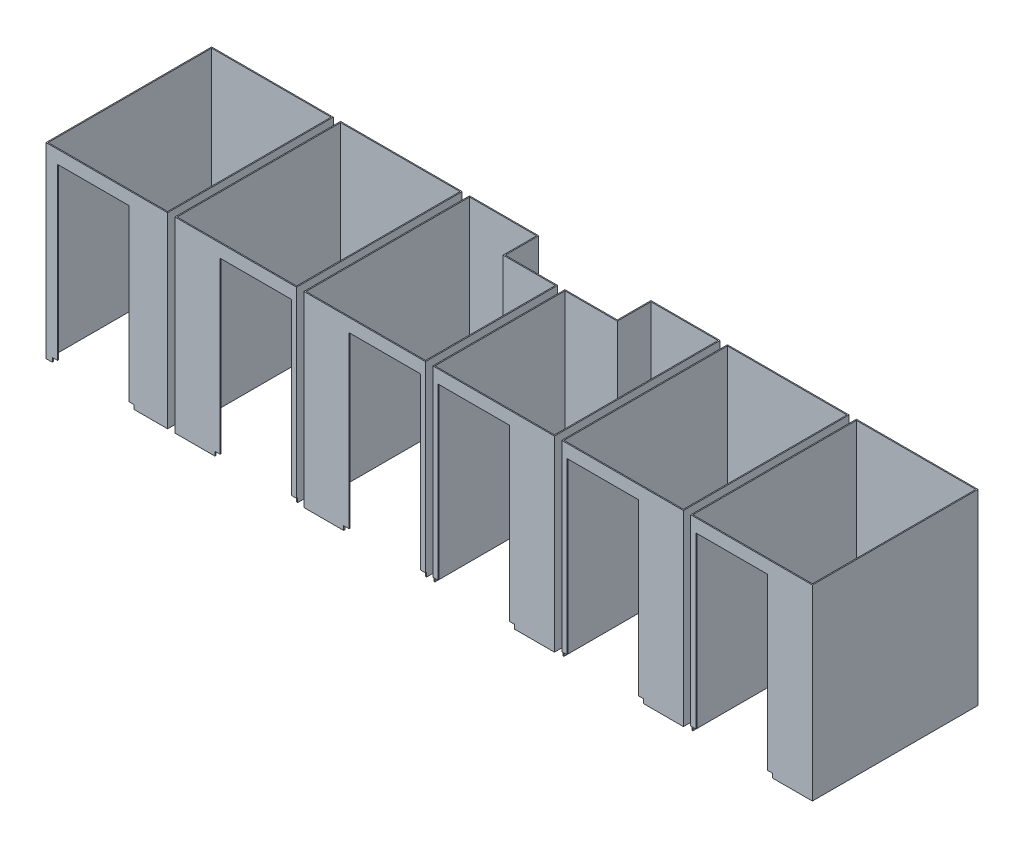
from build123d import *

# Parameters (mm, degrees)
SKETCH2_W             = 1473.2
SKETCH2_H             = 2006.6
SKETCH2_W_2           = 1447.8
SKETCH2_H_2           = 1981.2
BOSS_EXTRUDE1_DEPTH   = 2266.95
BOSS_EXTRUDE1_2_DEPTH = 2266.95
BOSS_EXTRUDE1_3_DEPTH = 2266.95
BOSS_EXTRUDE1_4_DEPTH = 2266.95
BOSS_EXTRUDE1_5_DEPTH = 2266.95
BOSS_EXTRUDE1_6_DEPTH = 2266.95
CUT_EXTRUDE1_DEPTH    = 12.7


with BuildPart() as part:
    # Sketch2 → Boss-Extrude1 (new body)
    with BuildSketch(Plane(origin=(0, 0, 0), x_dir=(1, 0, 0), z_dir=(0, 1, 0))):
        with Locations((2349.5, 1054.1)):
            Rectangle(SKETCH2_W, SKETCH2_H)
        with Locations((2349.5, 1054.1)):
            Rectangle(SKETCH2_W_2, SKETCH2_H_2, mode=Mode.SUBTRACT)
    extrude(amount=BOSS_EXTRUDE1_DEPTH)


with BuildPart() as body_2:
    # Sketch2 → Boss-Extrude1 2 (new body)
    with BuildSketch(Plane(origin=(0, 0, 0), x_dir=(1, 0, 0), z_dir=(0, 1, 0))):
        Polygon((4013.2, 1651), (4013.2, 2057.4), (3175, 2057.4), (3175, 50.8), (4648.2, 50.8), (4648.2, 1651), align=None)
        Polygon((3187.7, 63.5), (4635.5, 63.5), (4635.5, 1638.3), (4000.5, 1638.3), (4000.5, 2044.7), (3187.7, 2044.7), align=None, mode=Mode.SUBTRACT)
    extrude(amount=BOSS_EXTRUDE1_2_DEPTH)


with BuildPart() as body_3:
    # Sketch2 → Boss-Extrude1 3 (new body)
    with BuildSketch(Plane(origin=(0, 0, 0), x_dir=(1, 0, 0), z_dir=(0, 1, 0))):
        with Locations((787.4, 1054.1)):
            Rectangle(SKETCH2_W, SKETCH2_H)
        with Locations((787.4, 1054.1)):
            Rectangle(SKETCH2_W_2, SKETCH2_H_2, mode=Mode.SUBTRACT)
    extrude(amount=BOSS_EXTRUDE1_3_DEPTH)


with BuildPart() as body_4:
    # Sketch2 → Boss-Extrude1 4 (new body)
    with BuildSketch(Plane(origin=(0, 0, 0), x_dir=(1, 0, 0), z_dir=(0, 1, 0))):
        with Locations((7035.8, 1054.1)):
            Rectangle(SKETCH2_W, SKETCH2_H)
        with Locations((7035.8, 1054.1)):
            Rectangle(SKETCH2_W_2, SKETCH2_H_2, mode=Mode.SUBTRACT)
    extrude(amount=BOSS_EXTRUDE1_4_DEPTH)


with BuildPart() as body_5:
    # Sketch2 → Boss-Extrude1 5 (new body)
    with BuildSketch(Plane(origin=(0, 0, 0), x_dir=(1, 0, 0), z_dir=(0, 1, 0))):
        Polygon((5372.1, 2057.4), (5372.1, 1651), (4737.1, 1651), (4737.1, 50.8), (6210.3, 50.8), (6210.3, 2057.4), align=None)
        Polygon((5384.8, 1638.3), (4749.8, 1638.3), (4749.8, 63.5), (6197.6, 63.5), (6197.6, 2044.7), (5384.8, 2044.7), align=None, mode=Mode.SUBTRACT)
    extrude(amount=BOSS_EXTRUDE1_5_DEPTH)


with BuildPart() as body_6:
    # Sketch2 → Boss-Extrude1 6 (new body)
    with BuildSketch(Plane(origin=(0, 0, 0), x_dir=(1, 0, 0), z_dir=(0, 1, 0))):
        with Locations((8597.9, 1054.1)):
            Rectangle(SKETCH2_W, SKETCH2_H)
        with Locations((8597.9, 1054.1)):
            Rectangle(SKETCH2_W_2, SKETCH2_H_2, mode=Mode.SUBTRACT)
    extrude(amount=BOSS_EXTRUDE1_6_DEPTH)


with BuildPart() as cut_extrude1_tool:
    # Sketch3 → Cut-Extrude1 (new body)
    with BuildSketch(Plane.XY.offset(-50.8)):
        Polygon((127, 0), (1117.6, 0), (1117.6, 50.8), (1054.1, 50.8), (1054.1, 2108.2), (190.5, 2108.2), (190.5, 50.8), (127, 50.8), align=None)
        Polygon((2095.5, 0), (3086.1, 0), (3086.1, 50.8), (3022.6, 50.8), (3022.6, 2108.2), (2159, 2108.2), (2159, 50.8), (2095.5, 50.8), align=None)
        Polygon((3657.6, 50.8), (3657.6, 0), (4648.2, 0), (4648.2, 50.8), (4584.7, 50.8), (4584.7, 2108.2), (3721.1, 2108.2), (3721.1, 50.8), align=None)
        Polygon((4800.6, 50.8), (4737.1, 50.8), (4737.1, 0), (5727.7, 0), (5727.7, 50.8), (5664.2, 50.8), (5664.2, 2108.2), (4800.6, 2108.2), align=None)
        Polygon((6299.2, 50.8), (6299.2, 0), (7289.8, 0), (7289.8, 50.8), (7226.3, 50.8), (7226.3, 2108.2), (6362.7, 2108.2), (6362.7, 50.8), align=None)
        Polygon((7861.3, 50.8), (7861.3, 0), (8851.9, 0), (8851.9, 50.8), (8788.4, 50.8), (8788.4, 2108.2), (7924.8, 2108.2), (7924.8, 50.8), align=None)
    extrude(amount=-CUT_EXTRUDE1_DEPTH)


with BuildPart() as part_1:
    add(part.part)

    # Cut-Extrude1: cut by cut_extrude1_tool
    add(cut_extrude1_tool.part, mode=Mode.SUBTRACT)


with BuildPart() as body_2_1:
    add(body_2.part)

    # Cut-Extrude1: cut by cut_extrude1_tool
    add(cut_extrude1_tool.part, mode=Mode.SUBTRACT)


with BuildPart() as body_3_1:
    add(body_3.part)

    # Cut-Extrude1: cut by cut_extrude1_tool
    add(cut_extrude1_tool.part, mode=Mode.SUBTRACT)


with BuildPart() as body_4_1:
    add(body_4.part)

    # Cut-Extrude1: cut by cut_extrude1_tool
    add(cut_extrude1_tool.part, mode=Mode.SUBTRACT)


with BuildPart() as body_5_1:
    add(body_5.part)

    # Cut-Extrude1: cut by cut_extrude1_tool
    add(cut_extrude1_tool.part, mode=Mode.SUBTRACT)


with BuildPart() as body_6_1:
    add(body_6.part)

    # Cut-Extrude1: cut by cut_extrude1_tool
    add(cut_extrude1_tool.part, mode=Mode.SUBTRACT)


solid = Compound([part_1.part, body_2_1.part, body_3_1.part, body_4_1.part, body_5_1.part, body_6_1.part])
